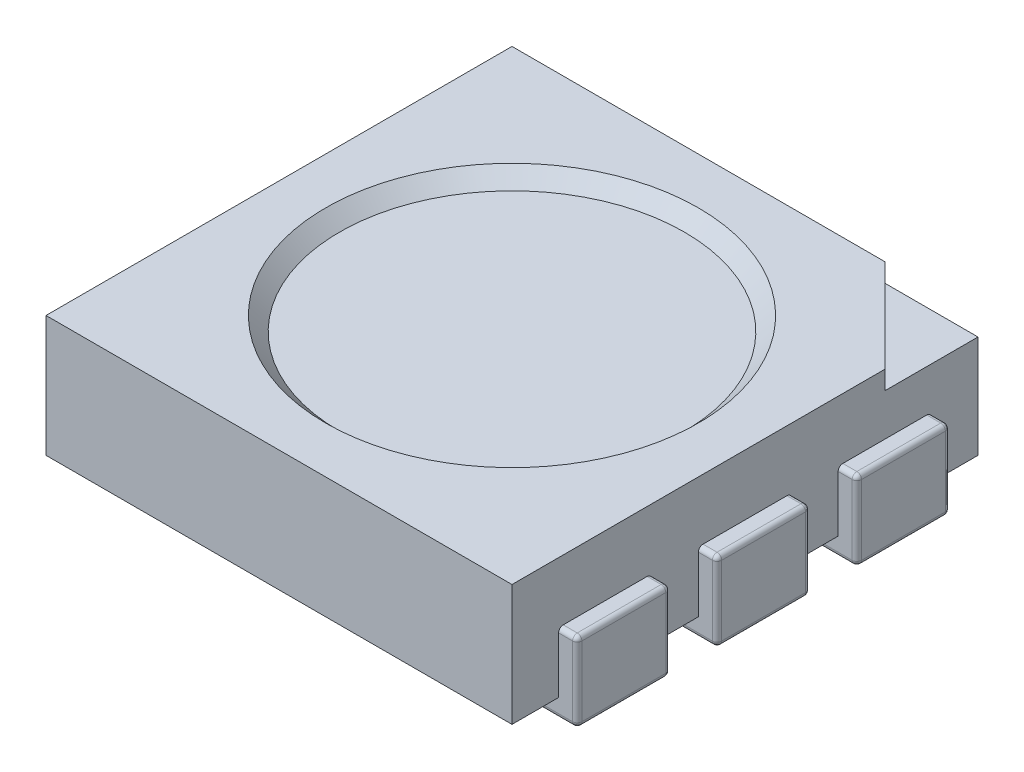
from build123d import *

# Parameters (mm, degrees)
SKETCH1_W                = 5
SKETCH1_H                = 5
BOSS_EXTRUDE1_DEPTH      = 1.3
CUT_EXTRUDE1_DEPTH       = 0.2
SKETCH3_R                = 2
CUT_EXTRUDE2_DEPTH       = 0.65
CUT_EXTRUDE2_TAPER       = 45
SKETCH4_W                = 1.4
SKETCH4_H                = 1
BOSS_EXTRUDE2_DEPTH      = 0.2
BOSS_EXTRUDE2_DEPTH_BACK = 0.65
SKETCH5_R                = 0.5
SKETCH5_W                = 1
SKETCH5_H                = 1.5
CUT_EXTRUDE3_DEPTH       = 0.1
SKETCH6_R                = 0.25
CUT_EXTRUDE4_DEPTH       = 0.1
SKETCH7_R                = 1.35
BOSS_EXTRUDE3_DEPTH      = 0.5
BOSS_EXTRUDE3_TAPER      = -45
FILLET2_R                = 0.05


with BuildPart() as part:
    # Sketch1 → Boss-Extrude1 (new body)
    with BuildSketch(Plane(origin=(0, 0, 0), x_dir=(1, 0, 0), z_dir=(0, 1, 0))):
        with Locations((2.5, 2.5)):
            Rectangle(SKETCH1_W, SKETCH1_H)
    extrude(amount=BOSS_EXTRUDE1_DEPTH)

    # Sketch2 → Cut-Extrude1 (cut)
    with BuildSketch(Plane(origin=(0, 1.3, 0), x_dir=(1, 0, 0), z_dir=(0, 1, 0))):
        Polygon((5, 5), (4, 5), (5, 4), align=None)
    extrude(amount=-CUT_EXTRUDE1_DEPTH, mode=Mode.SUBTRACT)

    # Sketch3 → Cut-Extrude2 (cut)
    with BuildSketch(Plane(origin=(0, 1.3, 0), x_dir=(1, 0, 0), z_dir=(0, 1, 0))):
        with Locations((2.5, 2.5)):
            Circle(SKETCH3_R)
    extrude(amount=-CUT_EXTRUDE2_DEPTH, taper=CUT_EXTRUDE2_TAPER, mode=Mode.SUBTRACT)

    # Sketch4 → Boss-Extrude2 (add, two sides)
    with BuildSketch(Plane.XZ) as boss_extrude2_sk:
        with Locations((0.5, -2.5)):
            Rectangle(SKETCH4_W, SKETCH4_H)
        with Locations((0.5, -1)):
            Rectangle(SKETCH4_W, SKETCH4_H)
        with Locations((0.5, -4)):
            Rectangle(SKETCH4_W, SKETCH4_H)
        with Locations((4.5, -4)):
            Rectangle(SKETCH4_W, SKETCH4_H)
        with Locations((4.5, -2.5)):
            Rectangle(SKETCH4_W, SKETCH4_H)
        with Locations((4.5, -1)):
            Rectangle(SKETCH4_W, SKETCH4_H)
    extrude(amount=BOSS_EXTRUDE2_DEPTH)
    extrude(boss_extrude2_sk.sketch, amount=-BOSS_EXTRUDE2_DEPTH_BACK)

    # Sketch5 → Cut-Extrude3 (cut)
    with BuildSketch(Plane.XZ):
        with Locations((2.5, -2.5)):
            Circle(SKETCH5_R)
        with Locations((2.5, -3.85)):
            Rectangle(SKETCH5_W, SKETCH5_H)
        with Locations((2.5, -1.15)):
            Rectangle(SKETCH5_W, SKETCH5_H)
    extrude(amount=-CUT_EXTRUDE3_DEPTH, mode=Mode.SUBTRACT)

    # Sketch6 → Cut-Extrude4 (cut)
    with BuildSketch(Plane.XZ.offset(-0.1)):
        with Locations((2.5, -2.5)):
            Circle(SKETCH6_R)
    extrude(amount=-CUT_EXTRUDE4_DEPTH, mode=Mode.SUBTRACT)

    # Sketch7 → Boss-Extrude3 (add)
    with BuildSketch(Plane(origin=(0, 0.65, 0), x_dir=(1, 0, 0), z_dir=(0, 1, 0))):
        with Locations((2.5, 2.5)):
            Circle(SKETCH7_R)
    extrude(amount=BOSS_EXTRUDE3_DEPTH, taper=BOSS_EXTRUDE3_TAPER)

    # Fillet2
    fillet2_edges = [part.edges().sort_by_distance(p)[0] for p in [
        (5.2, 0.225, -2),
        (5.1, 0.65, -2),
        (3.8, -0.1, -2),
        (5.1, 0.65, -3),
        (3.8, -0.1, -3),
        (5.2, 0.225, -3),
        (5.2, 0.65, -2.5),
        (4.5, -0.2, -2),
        (3.8, -0.2, -2.5),
        (4.5, -0.2, -3),
        (5.2, -0.2, -2.5),
        (5.2, 0.225, -0.5),
        (5.1, 0.65, -0.5),
        (3.8, -0.1, -0.5),
        (5.1, 0.65, -1.5),
        (3.8, -0.1, -1.5),
        (5.2, 0.225, -1.5),
        (5.2, 0.65, -1),
        (4.5, -0.2, -0.5),
        (3.8, -0.2, -1),
        (4.5, -0.2, -1.5),
        (5.2, -0.2, -1),
        (-0.1, 0.65, -1.5),
        (-0.2, 0.225, -1.5),
        (-0.1, 0.65, -0.5),
        (1.2, -0.1, -0.5),
        (-0.2, 0.225, -0.5),
        (-0.2, 0.65, -1),
        (1.2, -0.1, -1.5),
        (-0.2, -0.2, -1),
        (0.5, -0.2, -1.5),
        (1.2, -0.2, -1),
        (0.5, -0.2, -0.5),
        (-0.1, 0.65, -3),
        (-0.2, 0.225, -3),
        (-0.1, 0.65, -2),
        (1.2, -0.1, -2),
        (-0.2, 0.225, -2),
        (-0.2, 0.65, -2.5),
        (1.2, -0.1, -3),
        (-0.2, -0.2, -2.5),
        (0.5, -0.2, -3),
        (1.2, -0.2, -2.5),
        (0.5, -0.2, -2),
        (-0.1, 0.65, -4.5),
        (-0.2, 0.225, -4.5),
        (-0.1, 0.65, -3.5),
        (1.2, -0.1, -3.5),
        (-0.2, 0.225, -3.5),
        (-0.2, 0.65, -4),
        (1.2, -0.1, -4.5),
        (-0.2, -0.2, -4),
        (0.5, -0.2, -4.5),
        (1.2, -0.2, -4),
        (0.5, -0.2, -3.5),
        (5.2, 0.225, -3.5),
        (5.1, 0.65, -3.5),
        (3.8, -0.1, -3.5),
        (5.1, 0.65, -4.5),
        (3.8, -0.1, -4.5),
        (5.2, 0.225, -4.5),
        (5.2, 0.65, -4),
        (4.5, -0.2, -3.5),
        (3.8, -0.2, -4),
        (4.5, -0.2, -4.5),
        (5.2, -0.2, -4),
    ]]
    fillet(fillet2_edges, radius=FILLET2_R)


solid = part.part
